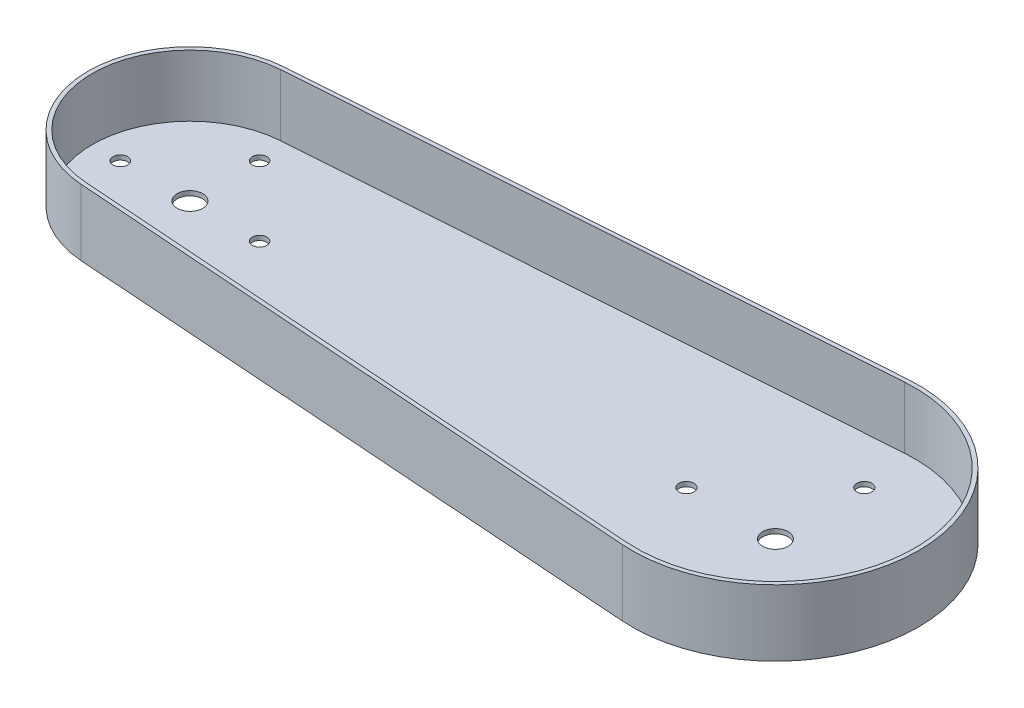
from build123d import *

# Parameters (mm, degrees)
SKETCH1_R           = 40
SKETCH1_R_2         = 2.85
SKETCH1_R_3         = 5
SKETCH1_R_4         = 56.3
SKETCH1_R_5         = 2.95
BOSS_EXTRUDE1_DEPTH = 26
CUT_EXTRUDE1_DEPTH  = 24.2


with BuildPart() as part:
    # Sketch1 → Boss-Extrude1 (new body)
    with BuildSketch(Plane(origin=(0, 0, 0), x_dir=(1, 0, 0), z_dir=(0, 1, 0))):
        with BuildLine():
            Line((226.010043478, 56.158438787), (-2.834782609, 39.899423649))
            ThreePointArc((-2.834782609, 39.899423649), (27.263608489, 29.269363713), (40, 0))
            ThreePointArc((40, 0), (27.263608489, -29.269363713), (-2.834782609, -39.899423649))
            Line((-2.834782609, -39.899423649), (226.010043478, -56.158438787))
            ThreePointArc((226.010043478, -56.158438787), (173.7, 0), (226.010043478, 56.158438787))
        make_face()
        Circle(SKETCH1_R)
        with Locations((-27.35, 0)):
            Circle(SKETCH1_R_2, mode=Mode.SUBTRACT)
        with Locations((0, -27.35)):
            Circle(SKETCH1_R_2, mode=Mode.SUBTRACT)
        with Locations((27.35, 0)):
            Circle(SKETCH1_R_2, mode=Mode.SUBTRACT)
        with Locations((0, 27.35)):
            Circle(SKETCH1_R_2, mode=Mode.SUBTRACT)
        Circle(SKETCH1_R_3, mode=Mode.SUBTRACT)
        with Locations((230, 0)):
            Circle(SKETCH1_R_4)
        with Locations((195.05, 0)):
            Circle(SKETCH1_R_5, mode=Mode.SUBTRACT)
        with Locations((230, -34.95)):
            Circle(SKETCH1_R_5, mode=Mode.SUBTRACT)
        with Locations((264.95, 0)):
            Circle(SKETCH1_R_5, mode=Mode.SUBTRACT)
        with Locations((230, 34.95)):
            Circle(SKETCH1_R_5, mode=Mode.SUBTRACT)
        with Locations((230, 0)):
            Circle(SKETCH1_R_3, mode=Mode.SUBTRACT)
    extrude(amount=BOSS_EXTRUDE1_DEPTH)

    # Sketch2 → Cut-Extrude1 (cut)
    with BuildSketch(Plane(origin=(0, 26, 0), x_dir=(1, 0, 0), z_dir=(0, 1, 0))):
        with BuildLine():
            Line((-2.721391304, -38.303446704), (226.123434783, -54.562461841))
            ThreePointArc((226.123434783, -54.562461841), (284.7, 0), (226.123434783, 54.562461841))
            Line((226.123434783, 54.562461841), (-2.721391304, 38.303446704))
            ThreePointArc((-2.721391304, 38.303446704), (-38.4, 0), (-2.721391304, -38.303446704))
        make_face()
    extrude(amount=-CUT_EXTRUDE1_DEPTH, mode=Mode.SUBTRACT)


solid = part.part
